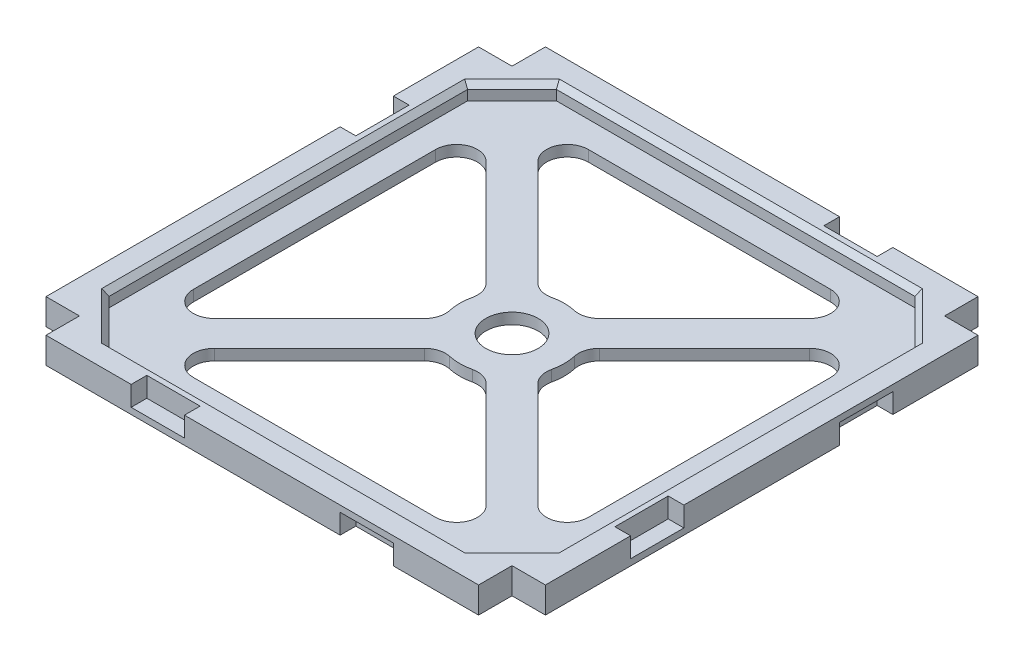
from build123d import *

# Parameters (mm, degrees)
SKETCH1_R           = 5
BOSS_EXTRUDE1_DEPTH = 2.1
BOSS_EXTRUDE2_DEPTH = 2.9
SKETCH3_W           = 10.2
SKETCH3_H           = 3.8
CUT_EXTRUDE1_DEPTH  = 3
CIRPATTERN1_COUNT   = 4
CHAMFER1_SIZE       = 1


with BuildPart() as part:
    # Sketch1 → Boss-Extrude1 (new body)
    with BuildSketch(Plane(origin=(0, 0, 0), x_dir=(1, 0, 0), z_dir=(0, 1, 0))):
        Polygon((-47.8, -41.4), (-47.8, 41.4), (-41.4, 41.4), (-41.4, 47.8), (41.4, 47.8), (41.4, 41.4), (47.8, 41.4), (47.8, -41.4), (41.4, -41.4), (41.4, -47.8), (-41.4, -47.8), (-41.4, -41.4), align=None)
        Circle(SKETCH1_R, mode=Mode.SUBTRACT)
        with BuildLine():
            Line((-30.971572875, -26.021825407), (-10.834000483, -5.884253014))
            ThreePointArc((-10.834000483, -5.884253014), (-9.821178524, -4.171534398), (-9.758876863, -2.182732778))
            ThreePointArc((-9.758876863, -2.182732778), (-10, 0), (-9.758876863, 2.182732778))
            ThreePointArc((-9.758876863, 2.182732778), (-9.821178524, 4.171534398), (-10.834000483, 5.884253014))
            Line((-10.834000483, 5.884253014), (-30.971572875, 26.021825407))
            ThreePointArc((-30.971572875, 26.021825407), (-35.330733729, 26.888916412), (-37.8, 23.193398282))
            Line((-37.8, 23.193398282), (-37.8, -23.193398282))
            ThreePointArc((-37.8, -23.193398282), (-35.330733729, -26.888916412), (-30.971572875, -26.021825407))
        make_face(mode=Mode.SUBTRACT)
        with BuildLine():
            Line((-26.021825407, -30.971572875), (-5.884253014, -10.834000483))
            ThreePointArc((-5.884253014, -10.834000483), (-4.171534398, -9.821178524), (-2.182732778, -9.758876863))
            ThreePointArc((-2.182732778, -9.758876863), (0, -10), (2.182732778, -9.758876863))
            ThreePointArc((2.182732778, -9.758876863), (4.171534398, -9.821178524), (5.884253014, -10.834000483))
            Line((5.884253014, -10.834000483), (26.021825407, -30.971572875))
            ThreePointArc((26.021825407, -30.971572875), (26.888916412, -35.330733729), (23.193398282, -37.8))
            Line((23.193398282, -37.8), (-23.193398282, -37.8))
            ThreePointArc((-23.193398282, -37.8), (-26.888916412, -35.330733729), (-26.021825407, -30.971572875))
        make_face(mode=Mode.SUBTRACT)
        with BuildLine():
            Line((30.971572875, -26.021825407), (10.834000483, -5.884253014))
            ThreePointArc((10.834000483, -5.884253014), (9.821178524, -4.171534398), (9.758876863, -2.182732778))
            ThreePointArc((9.758876863, -2.182732778), (10, 0), (9.758876863, 2.182732778))
            ThreePointArc((9.758876863, 2.182732778), (9.821178524, 4.171534398), (10.834000483, 5.884253014))
            Line((10.834000483, 5.884253014), (30.971572875, 26.021825407))
            ThreePointArc((30.971572875, 26.021825407), (35.330733729, 26.888916412), (37.8, 23.193398282))
            Line((37.8, 23.193398282), (37.8, -23.193398282))
            ThreePointArc((37.8, -23.193398282), (35.330733729, -26.888916412), (30.971572875, -26.021825407))
        make_face(mode=Mode.SUBTRACT)
        with BuildLine():
            Line((-26.021825407, 30.971572875), (-5.884253014, 10.834000483))
            ThreePointArc((-5.884253014, 10.834000483), (-4.171534398, 9.821178524), (-2.182732778, 9.758876863))
            ThreePointArc((-2.182732778, 9.758876863), (0, 10), (2.182732778, 9.758876863))
            ThreePointArc((2.182732778, 9.758876863), (4.171534398, 9.821178524), (5.884253014, 10.834000483))
            Line((5.884253014, 10.834000483), (26.021825407, 30.971572875))
            ThreePointArc((26.021825407, 30.971572875), (26.888916412, 35.330733729), (23.193398282, 37.8))
            Line((23.193398282, 37.8), (-23.193398282, 37.8))
            ThreePointArc((-23.193398282, 37.8), (-26.888916412, 35.330733729), (-26.021825407, 30.971572875))
        make_face(mode=Mode.SUBTRACT)
    extrude(amount=BOSS_EXTRUDE1_DEPTH)

    # Sketch2 → Boss-Extrude2 (add)
    with BuildSketch(Plane(origin=(0, 2.1, 0), x_dir=(1, 0, 0), z_dir=(0, 1, 0))):
        Polygon((-47.8, -41.4), (-41.4, -41.4), (-41.4, -47.8), (41.4, -47.8), (41.4, -41.4), (47.8, -41.4), (47.8, 41.4), (41.4, 41.4), (41.4, 47.8), (-41.4, 47.8), (-41.4, 41.4), (-47.8, 41.4), align=None)
        Polygon((-42.8, 34.314718626), (-42.8, -34.314718626), (-34.314718626, -42.8), (34.314718626, -42.8), (42.8, -34.314718626), (42.8, 34.314718626), (34.314718626, 42.8), (-34.314718626, 42.8), align=None, mode=Mode.SUBTRACT)
    extrude(amount=BOSS_EXTRUDE2_DEPTH)

    # Sketch3 → Cut-Extrude1 (cut)
    with BuildSketch(Plane.ZY.offset(47.8)):
        with Locations((20, 1.9)):
            Rectangle(SKETCH3_W, SKETCH3_H)
        with Locations((-20, 3.1)):
            Rectangle(SKETCH3_W, SKETCH3_H)
    cut_extrude1 = extrude(amount=-CUT_EXTRUDE1_DEPTH, mode=Mode.SUBTRACT)

    # CirPattern1: Cut-Extrude1 ×4 about axis
    cirpattern1_axis = Axis((0, 0, 0), (0, 1, 0))
    for i in range(1, CIRPATTERN1_COUNT):
        add(cut_extrude1.rotate(cirpattern1_axis, i * 360 / CIRPATTERN1_COUNT), mode=Mode.SUBTRACT)

    # Chamfer1
    chamfer1_edges = [part.edges().sort_by_distance(p)[0] for p in [
        (-38.557359313, 5, -38.557359313),
        (-42.8, 5, 0),
        (-38.557359313, 5, 38.557359313),
        (0, 5, 42.8),
        (38.557359313, 5, 38.557359313),
        (42.8, 5, 0),
        (38.557359313, 5, -38.557359313),
        (0, 5, -42.8),
    ]]
    chamfer(chamfer1_edges, length=CHAMFER1_SIZE)


solid = part.part
